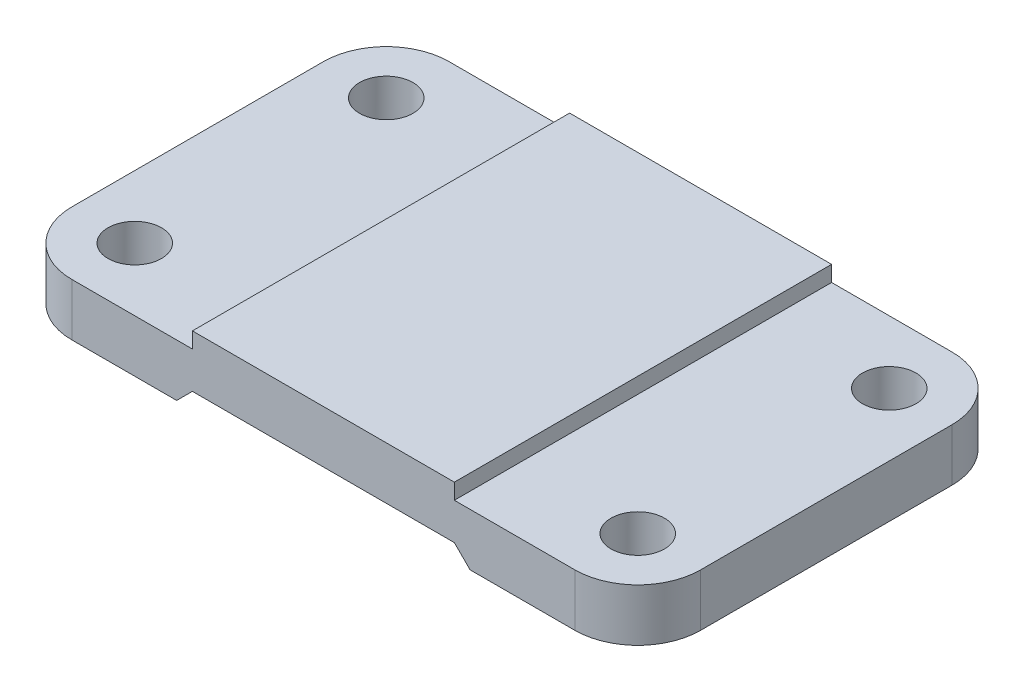
from build123d import *

# Parameters (mm, degrees)
SKETCH1_W              = 120
SKETCH1_H              = 72
BOSS_EXTRUDE1_DEPTH    = 10
FILLET1_R              = 12
M12_TAPPED_HOLE1_D     = 10.2
M12_TAPPED_HOLE1_DEPTH = 10
SKETCH4_W              = 50
SKETCH4_H              = 72
BOSS_EXTRUDE2_DEPTH    = 3
CUT_EXTRUDE1_DEPTH     = 73


with BuildPart() as part:
    # Sketch1 → Boss-Extrude1 (new body)
    with BuildSketch(Plane(origin=(0, 0, 0), x_dir=(1, 0, 0), z_dir=(0, 1, 0))):
        Rectangle(SKETCH1_W, SKETCH1_H)
    extrude(amount=BOSS_EXTRUDE1_DEPTH)

    # Fillet1
    fillet1_edges = [part.edges().sort_by_distance(p)[0] for p in [
        (60, 5, 36),
        (-60, 5, 36),
        (-60, 5, -36),
        (60, 5, -36),
    ]]
    fillet(fillet1_edges, radius=FILLET1_R)

    # M12 Tapped Hole1
    with Locations(Plane(origin=(0, 10, 0), x_dir=(1, 0, 0), z_dir=(0, 1, 0))):
        with Locations((48, -24), (48, 24), (-48, 24), (-48, -24)):
            Hole(M12_TAPPED_HOLE1_D / 2, depth=M12_TAPPED_HOLE1_DEPTH)

    # Sketch4 → Boss-Extrude2 (add)
    with BuildSketch(Plane(origin=(0, 10, 0), x_dir=(1, 0, 0), z_dir=(0, 1, 0))):
        Rectangle(SKETCH4_W, SKETCH4_H)
    extrude(amount=BOSS_EXTRUDE2_DEPTH)

    # Sketch5 → Cut-Extrude1 (cut, through all)
    with BuildSketch(Plane.XY.offset(36)):
        Polygon((-28, 0), (-25, 3), (25, 3), (28, 0), align=None)
    extrude(amount=-CUT_EXTRUDE1_DEPTH, mode=Mode.SUBTRACT)


solid = part.part
